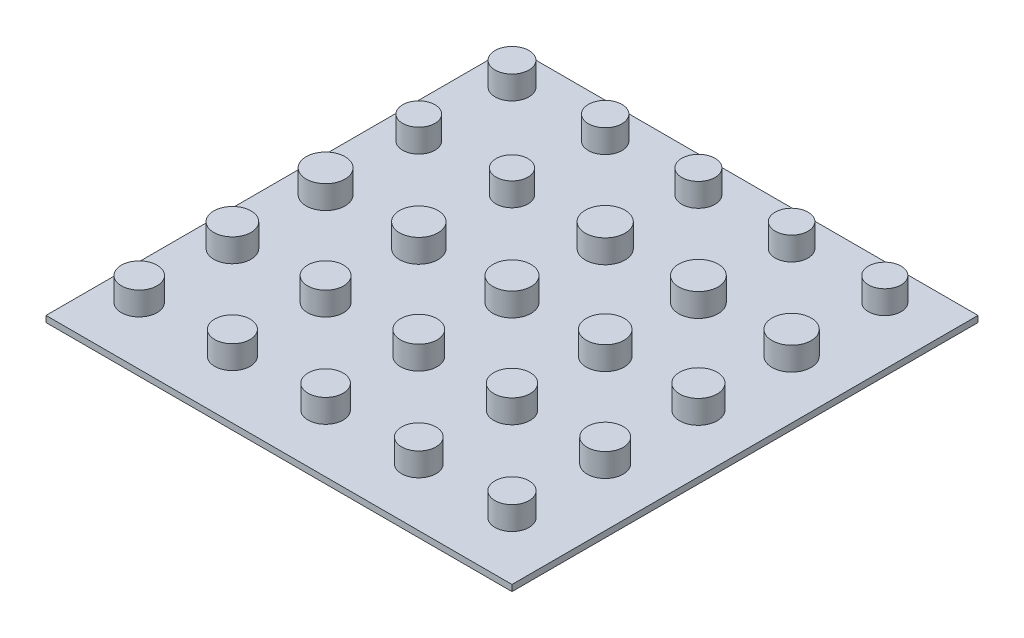
from build123d import *

# Parameters (mm, degrees)
SKETCH1_W           = 38.1
SKETCH1_H           = 38.1
BOSS_EXTRUDE1_DEPTH = 0.508
SKETCH2_R           = 1.3843
SKETCH2_R_2         = 1.3716
SKETCH2_R_3         = 1.3589
SKETCH2_R_4         = 1.3462
SKETCH2_R_5         = 1.3335
SKETCH2_R_6         = 1.3081
SKETCH2_R_7         = 1.6256
SKETCH2_R_8         = 1.6129
SKETCH2_R_9         = 1.6002
SKETCH2_R_10        = 1.5748
SKETCH2_R_11        = 1.5621
SKETCH2_R_12        = 1.5494
SKETCH2_R_13        = 1.5367
SKETCH2_R_14        = 1.4732
SKETCH2_R_15        = 1.4986
SKETCH2_R_16        = 1.4859
SKETCH2_R_17        = 1.4478
SKETCH2_R_18        = 1.4351
SKETCH2_R_19        = 1.4097
SKETCH2_R_20        = 1.397
SKETCH2_R_21        = 1.3208
SKETCH2_R_22        = 1.5875
SKETCH2_R_23        = 1.524
SKETCH2_R_24        = 1.4605
BOSS_EXTRUDE2_DEPTH = 1.905


with BuildPart() as part:
    # Sketch1 → Boss-Extrude1 (new body)
    with BuildSketch(Plane(origin=(0, 0, 0), x_dir=(1, 0, 0), z_dir=(0, 1, 0))):
        Rectangle(SKETCH1_W, SKETCH1_H)
    extrude(amount=BOSS_EXTRUDE1_DEPTH)

    # Sketch2 → Boss-Extrude2 (add)
    with BuildSketch(Plane(origin=(0, 0.508, 0), x_dir=(1, 0, 0), z_dir=(0, 1, 0))):
        with Locations((-16.163328468, 16.163328468)):
            Circle(SKETCH2_R)
        with Locations((-8.543328468, 16.163328468)):
            Circle(SKETCH2_R_2)
        with Locations((-0.923328468, 16.163328468)):
            Circle(SKETCH2_R_3)
        with Locations((6.696671532, 16.163328468)):
            Circle(SKETCH2_R_4)
        with Locations((14.316671532, 16.163328468)):
            Circle(SKETCH2_R_5)
        with Locations((-8.543328468, 8.543328468)):
            Circle(SKETCH2_R_6)
        with Locations((-0.923328468, 8.543328468)):
            Circle(SKETCH2_R_7)
        with Locations((6.696671532, 8.543328468)):
            Circle(SKETCH2_R_8)
        with Locations((14.316671532, 8.543328468)):
            Circle(SKETCH2_R_9)
        with Locations((-8.543328468, 0.923328468)):
            Circle(SKETCH2_R_10)
        with Locations((-0.923328468, 0.923328468)):
            Circle(SKETCH2_R_11)
        with Locations((6.696671532, 0.923328468)):
            Circle(SKETCH2_R_12)
        with Locations((14.316671532, 0.923328468)):
            Circle(SKETCH2_R_13)
        with Locations((-8.543328468, -6.696671532)):
            Circle(SKETCH2_R_14)
        with Locations((-0.923328468, -6.696671532)):
            Circle(SKETCH2_R_15)
        with Locations((6.696671532, -6.696671532)):
            Circle(SKETCH2_R_16)
        with Locations((14.316671532, -6.696671532)):
            Circle(SKETCH2_R_14)
        with Locations((-8.543328468, -14.316671532)):
            Circle(SKETCH2_R_17)
        with Locations((-0.923328468, -14.316671532)):
            Circle(SKETCH2_R_18)
        with Locations((6.696671532, -14.316671532)):
            Circle(SKETCH2_R_19)
        with Locations((14.316671532, -14.316671532)):
            Circle(SKETCH2_R_20)
        with Locations((-16.163328468, 8.543328468)):
            Circle(SKETCH2_R_21)
        with Locations((-16.163328468, 0.923328468)):
            Circle(SKETCH2_R_22)
        with Locations((-16.163328468, -6.696671532)):
            Circle(SKETCH2_R_23)
        with Locations((-16.163328468, -14.316671532)):
            Circle(SKETCH2_R_24)
    extrude(amount=BOSS_EXTRUDE2_DEPTH)


solid = part.part
